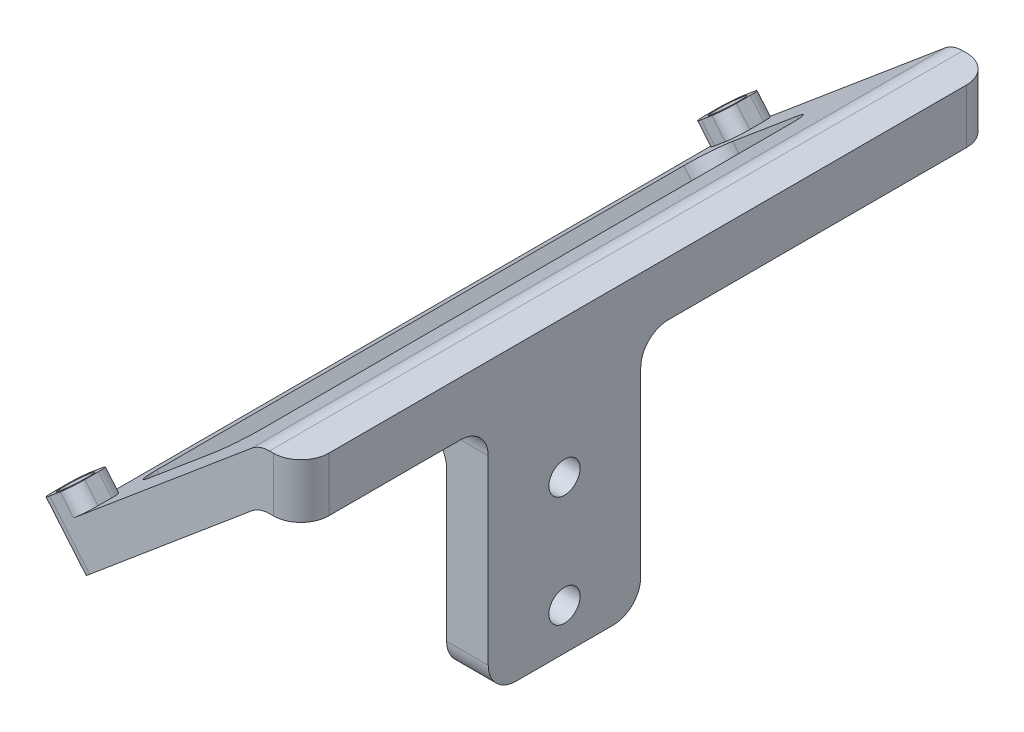
from build123d import *

# Parameters (mm, degrees)
BOSS_EXTRU_1_DEPTH           = 100
ESQUISSE2_W                  = 6
ESQUISSE2_H                  = 6.000000000000014
ESQUISSE2_H_2                = 6.000000000000005
BOSS_EXTRU_2_DEPTH           = 3
ESQUISSE3_R                  = 2.2500000000000027
ESQUISSE3_R_2                = 2.250000000000001
ENL_V_MAT_EXTRU_1_DEPTH      = 5
ENL_V_MAT_EXTRU_2_DEPTH      = 106.73176853427184
ENL_V_MAT_EXTRU_2_DEPTH_BACK = 106.73176853427184
ESQUISSE4_R                  = 1.7500000000000013
ESQUISSE4_R_2                = 1.75
CONG_1_R                     = 2
ENL_V_MAT_EXTRU_3_DEPTH      = 6
CONG_2_R                     = 4
ENL_V_MAT_EXTRU_5_DEPTH      = 6.000001
CONG_3_R                     = 4
ESQUISSE7_R                  = 2.2500000000000027
ESQUISSE7_R_2                = 2.250000000000002
ENL_V_MAT_EXTRU_6_DEPTH      = 6


with BuildPart() as part:
    # Esquisse1 → Boss.-Extru.1 (new body)
    with BuildSketch(Plane.XY):
        Polygon((0, 0), (0, 34.167556264006286), (-26.019007623520746, 12.33501656351095), (-29.875733281640006, 16.9312832222248), (0, 42), (5.999999999999995, 42), (6, 2.4e-16), align=None)
    extrude(amount=BOSS_EXTRU_1_DEPTH)

    # Esquisse2 → Boss.-Extru.2 (add)
    with BuildSketch(Plane(origin=(-20.680962813256418, 24.64661173100532, 0), x_dir=(0.7660444431189743, 0.6427876096865438, 0), z_dir=(-0.6427876096865438, 0.7660444431189745, 0))):
        with Locations((-9.002920393165164, -97)):
            Rectangle(ESQUISSE2_W, ESQUISSE2_H)
        with Locations((-9.002920393165164, -3.0000000000000027)):
            Rectangle(ESQUISSE2_W, ESQUISSE2_H_2)
    extrude(amount=BOSS_EXTRU_2_DEPTH)

    # Esquisse3 → Enlèv. mat.-Extru.1 (cut)
    with BuildSketch(Plane(origin=(-22.609325642316065, 26.94474506036225, 0), x_dir=(0.7660444431189746, 0.6427876096865436, 0), z_dir=(-0.6427876096865435, 0.7660444431189745, 0))):
        with Locations(Location((-9.002920393165152, -97, 0), (0, 0, 180))):
            Circle(ESQUISSE3_R)
        with Locations(Location((-9.002920393165152, -3.0000000000000027, 0), (0, 0, 180))):
            Circle(ESQUISSE3_R_2)
    extrude(amount=-ENL_V_MAT_EXTRU_1_DEPTH, mode=Mode.SUBTRACT)

    # Esquisse4 → Enlèv. mat.-Extru.2 (cut, two sides: drawn at the far end of the back side and taken through both)
    with BuildSketch(Plane(origin=(-19.395387593883342, 23.114522844767386, 0), x_dir=(0.7660444431189743, 0.6427876096865437, 0), z_dir=(-0.6427876096865437, 0.7660444431189743, 0)).offset(-ENL_V_MAT_EXTRU_2_DEPTH_BACK)):
        with Locations(Location((-9.002920393165155, -97, 0), (0, 0, 180))):
            Circle(ESQUISSE4_R)
        with Locations(Location((-9.002920393165155, -3.0000000000000027, 0), (0, 0, 180))):
            Circle(ESQUISSE4_R_2)
    extrude(amount=ENL_V_MAT_EXTRU_2_DEPTH + ENL_V_MAT_EXTRU_2_DEPTH_BACK, mode=Mode.SUBTRACT)

    # Congé1
    cong_1_edges = [part.edges().sort_by_distance(p)[0] for p in [
        (-28.91155186711019, 15.782216557546342, 100),
        (-30.83991469616982, 18.080349886903274, 94),
        (-26.243648037455976, 21.937075545022537, 100),
        (-26.243648037455976, 21.937075545022537, 94),
        (-26.243648037455976, 21.937075545022537, 0),
        (-30.83991469616982, 18.080349886903274, 6.000000000000005),
        (-26.243648037455976, 21.937075545022537, 6.000000000000005),
        (-28.91155186711019, 15.782216557546342, 0),
    ]]
    fillet(cong_1_edges, radius=CONG_1_R)

    # Esquisse5 → Enlèv. mat.-Extru.3 (cut)
    with BuildSketch(Plane(origin=(6, 7.4e-16, 0), x_dir=(0, 0, -1), z_dir=(1, 1.2e-16, 0))):
        Polygon((-100, -4.5e-16), (-73.00000000000001, 0), (-73.00000000000001, 34.167556264006286), (-100, 34.167556264006286), align=None)
        Polygon((0, 0), (-51, -6.25e-15), (-51, 34.167556264006286), (0, 34.167556264006286), align=None)
    extrude(amount=-ENL_V_MAT_EXTRU_3_DEPTH, mode=Mode.SUBTRACT)

    # Congé2
    cong_2_edges = [part.edges().sort_by_distance(p)[0] for p in [
        (0, 34.167556264006286, 62.00000000000001),
    ]]
    fillet(cong_2_edges, radius=CONG_2_R)

    # Esquisse6 → Enlèv. mat.-Extru.5 (cut)
    with BuildSketch(Plane(origin=(-20.68096281325642, 24.646611731005315, 0), x_dir=(0.7660444431189746, 0.6427876096865437, 0), z_dir=(-0.6427876096865437, 0.7660444431189746, 0))):
        Polygon((-8.002920393165189, -8.000000000000007), (11.997079606834813, -8.000000000000007), (11.997079606834824, -92), (-8.002920393165178, -92), align=None)
    extrude(amount=-ENL_V_MAT_EXTRU_5_DEPTH, mode=Mode.SUBTRACT)

    # Congé3
    cong_3_edges = [part.edges().sort_by_distance(p)[0] for p in [
        (0, 34.167556264006286, 86.5),
        (0, 42, 50),
        (5.999999999999996, 38.08377813200315, 100),
        (2.9999999999999964, 34.167556264006286, 73.00000000000001),
        (3, 4e-16, 73.00000000000001),
        (5.999999999999996, 38.08377813200315, 0),
        (3, -5.85e-15, 51),
        (0, 34.167556264006286, 25.5),
        (2.9999999999999964, 34.167556264006286, 51),
        (-24.88319268010449, 17.204300331614043, 92),
        (-24.8831926801045, 17.20430033161404, 8.000000000000007),
        (-9.562303817725006, 30.060052525344915, 8.000000000000007),
        (-9.562303817724995, 30.060052525344922, 92),
    ]]
    fillet(cong_3_edges, radius=CONG_3_R)

    # Esquisse7 → Enlèv. mat.-Extru.6 (cut)
    with BuildSketch(Plane(origin=(6, 7.4e-16, 0), x_dir=(0, 0, -1), z_dir=(1, 1.3e-16, 0))):
        with Locations(Location((-62, 22, 0), (0, 0, 90))):
            Circle(ESQUISSE7_R)
        with Locations(Location((-62, 6, 0), (0, 0, 90))):
            Circle(ESQUISSE7_R_2)
    extrude(amount=-ENL_V_MAT_EXTRU_6_DEPTH, mode=Mode.SUBTRACT)


solid = part.part
